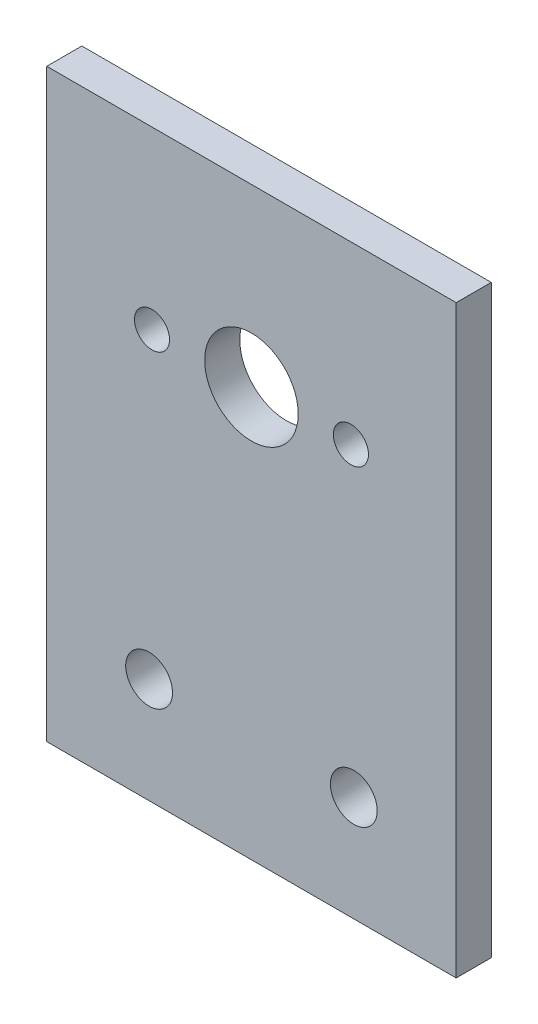
from build123d import *

# Parameters (mm, degrees)
SKETCH1_W           = 35
SKETCH1_H           = 50
SKETCH1_R           = 2
SKETCH1_R_2         = 4
SKETCH1_R_3         = 1.5
BOSS_EXTRUDE1_DEPTH = 3


with BuildPart() as part:
    # Sketch1 → Boss-Extrude1 (new body)
    with BuildSketch(Plane.XY):
        Rectangle(SKETCH1_W, SKETCH1_H)
        with Locations((8.75, -16)):
            Circle(SKETCH1_R, mode=Mode.SUBTRACT)
        with Locations((-8.75, -16)):
            Circle(SKETCH1_R, mode=Mode.SUBTRACT)
        with Locations((0, 10)):
            Circle(SKETCH1_R_2, mode=Mode.SUBTRACT)
        with Locations((8.5, 10)):
            Circle(SKETCH1_R_3, mode=Mode.SUBTRACT)
        with Locations((-8.5, 10)):
            Circle(SKETCH1_R_3, mode=Mode.SUBTRACT)
    extrude(amount=BOSS_EXTRUDE1_DEPTH)


solid = part.part
